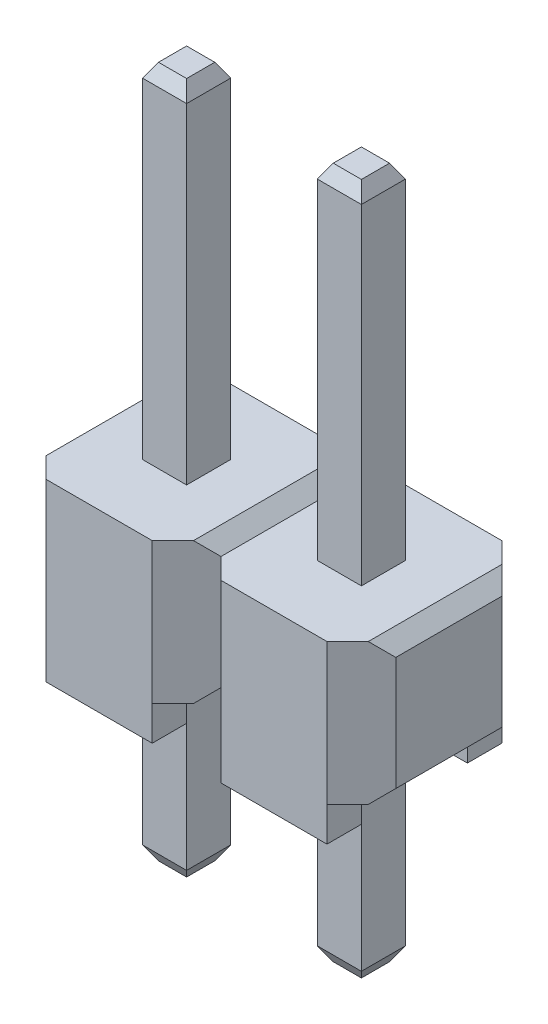
from build123d import *

# Parameters (mm, degrees)
SKETCH1_W                = 0.64
SKETCH1_H                = 0.64
BOSS_EXTRUDE1_DEPTH      = 2.05
CUT_EXTRUDE1_DEPTH       = 5
SKETCH3_W                = 1.54
SKETCH3_H                = 0.5
BOSS_EXTRUDE2_DEPTH      = 0.5
SKETCH4_W                = 0.64
SKETCH4_H                = 0.64
BOSS_EXTRUDE3_DEPTH      = 5
BOSS_EXTRUDE3_DEPTH_BACK = 5.05
CHAMFER1_SIZE            = 0.2
CHAMFER1_SIZE2           = 0.115470054
CHAMFER1_PART_2_SIZE     = 0.2
CHAMFER1_PART_2_SIZE2    = 0.115470054
CHAMFER1_PART_3_SIZE     = 0.2
CHAMFER1_PART_3_SIZE2    = 0.115470054
CHAMFER1_PART_4_SIZE     = 0.2
CHAMFER1_PART_4_SIZE2    = 0.115470054
CHAMFER1_PART_5_SIZE     = 0.2
CHAMFER1_PART_5_SIZE2    = 0.115470054
CHAMFER1_PART_6_SIZE     = 0.2
CHAMFER1_PART_6_SIZE2    = 0.115470054
CHAMFER1_PART_7_SIZE     = 0.2
CHAMFER1_PART_7_SIZE2    = 0.115470054
CHAMFER1_PART_8_SIZE     = 0.2
CHAMFER1_PART_8_SIZE2    = 0.115470054
CHAMFER1_PART_9_SIZE     = 0.2
CHAMFER1_PART_9_SIZE2    = 0.115470054
CHAMFER1_PART_10_SIZE    = 0.2
CHAMFER1_PART_10_SIZE2   = 0.115470054
CHAMFER1_PART_11_SIZE    = 0.2
CHAMFER1_PART_11_SIZE2   = 0.115470054
CHAMFER1_PART_12_SIZE    = 0.2
CHAMFER1_PART_12_SIZE2   = 0.115470054
CHAMFER1_PART_13_SIZE    = 0.2
CHAMFER1_PART_13_SIZE2   = 0.115470054
CHAMFER1_PART_14_SIZE    = 0.2
CHAMFER1_PART_14_SIZE2   = 0.115470054
CHAMFER1_PART_15_SIZE    = 0.2
CHAMFER1_PART_15_SIZE2   = 0.115470054
CHAMFER1_PART_16_SIZE    = 0.2
CHAMFER1_PART_16_SIZE2   = 0.115470054
SKETCH5_R                = 0.125
CUT_EXTRUDE2_DEPTH       = 1


with BuildPart() as part:
    # Sketch1 → Boss-Extrude1 (new body)
    with BuildSketch(Plane(origin=(0, 0, 0), x_dir=(1, 0, 0), z_dir=(0, 1, 0))):
        Polygon((-2.04, -1.27), (-0.5, -1.27), (0, -0.77), (0.5, -1.27), (2.04, -1.27), (2.54, -0.77), (2.54, 0.77), (2.04, 1.27), (0.5, 1.27), (0, 0.77), (-0.5, 1.27), (-2.04, 1.27), (-2.54, 0.77), (-2.54, -0.77), align=None)
        with Locations((1.27, 0)):
            Rectangle(SKETCH1_W, SKETCH1_H, mode=Mode.SUBTRACT)
        with Locations((-1.27, 0)):
            Rectangle(SKETCH1_W, SKETCH1_H, mode=Mode.SUBTRACT)
    extrude(amount=-BOSS_EXTRUDE1_DEPTH)

    # Sketch2 → Cut-Extrude1 (cut, symmetric)
    with BuildSketch(Plane.XY):
        Polygon((-2.54, -0.2), (-2.54, 0), (-2.34, 0), align=None)
        Polygon((-0.2, 0), (0.2, 0), (0, -0.2), align=None)
        Polygon((2.34, 0), (2.54, 0), (2.54, -0.2), align=None)
        Polygon((-2.54, -1.85), (-2.34, -2.05), (-2.54, -2.05), align=None)
        Polygon((-0.2, -2.05), (0, -1.85), (0.2, -2.05), align=None)
        Polygon((2.34, -2.05), (2.54, -1.85), (2.54, -2.05), align=None)
    extrude(amount=CUT_EXTRUDE1_DEPTH, both=True, mode=Mode.SUBTRACT)

    # Sketch3 → Boss-Extrude2 (add)
    with BuildSketch(Plane.XZ.offset(2.05)):
        with Locations((-1.27, -1.02)):
            Rectangle(SKETCH3_W, SKETCH3_H)
        with Locations((-1.27, 1.02)):
            Rectangle(SKETCH3_W, SKETCH3_H)
        with Locations((1.27, 1.02)):
            Rectangle(SKETCH3_W, SKETCH3_H)
        with Locations((1.27, -1.02)):
            Rectangle(SKETCH3_W, SKETCH3_H)
    extrude(amount=BOSS_EXTRUDE2_DEPTH)

    # Sketch4 → Boss-Extrude3 (add, two sides)
    with BuildSketch(Plane(origin=(0, 0, 0), x_dir=(1, 0, 0), z_dir=(0, 1, 0))) as boss_extrude3_sk:
        with Locations((-1.27, 0)):
            Rectangle(SKETCH4_W, SKETCH4_H)
        with Locations((1.27, 0)):
            Rectangle(SKETCH4_W, SKETCH4_H)
    extrude(amount=BOSS_EXTRUDE3_DEPTH)
    extrude(boss_extrude3_sk.sketch, amount=-BOSS_EXTRUDE3_DEPTH_BACK)

    # Chamfer1
    chamfer1_edges = [part.edges().sort_by_distance(p)[0] for p in [
        (-1.59, -5.05, 0),
    ]]
    chamfer1_side = [part.faces().sort_by_distance(p)[0] for p in [
        (-1.59, -3.55, 0),
    ]]
    chamfer(chamfer1_edges, length=CHAMFER1_SIZE, length2=CHAMFER1_SIZE2, reference=chamfer1_side[0])

    # Chamfer1 part 2
    chamfer1_part_2_edges = [part.edges().sort_by_distance(p)[0] for p in [
        (-1.27, -5.05, -0.32),
    ]]
    chamfer1_part_2_side = [part.faces().sort_by_distance(p)[0] for p in [
        (-1.27, -3.55, -0.32),
    ]]
    chamfer(chamfer1_part_2_edges, length=CHAMFER1_PART_2_SIZE, length2=CHAMFER1_PART_2_SIZE2, reference=chamfer1_part_2_side[0])

    # Chamfer1 part 3
    chamfer1_part_3_edges = [part.edges().sort_by_distance(p)[0] for p in [
        (-0.95, -5.05, 0),
    ]]
    chamfer1_part_3_side = [part.faces().sort_by_distance(p)[0] for p in [
        (-0.95, -3.55, 0),
    ]]
    chamfer(chamfer1_part_3_edges, length=CHAMFER1_PART_3_SIZE, length2=CHAMFER1_PART_3_SIZE2, reference=chamfer1_part_3_side[0])

    # Chamfer1 part 4
    chamfer1_part_4_edges = [part.edges().sort_by_distance(p)[0] for p in [
        (-1.27, -5.05, 0.32),
    ]]
    chamfer1_part_4_side = [part.faces().sort_by_distance(p)[0] for p in [
        (-1.27, -3.55, 0.32),
    ]]
    chamfer(chamfer1_part_4_edges, length=CHAMFER1_PART_4_SIZE, length2=CHAMFER1_PART_4_SIZE2, reference=chamfer1_part_4_side[0])

    # Chamfer1 part 5
    chamfer1_part_5_edges = [part.edges().sort_by_distance(p)[0] for p in [
        (-1.59, 5, 0),
    ]]
    chamfer1_part_5_side = [part.faces().sort_by_distance(p)[0] for p in [
        (-1.59, 2.5, 0),
    ]]
    chamfer(chamfer1_part_5_edges, length=CHAMFER1_PART_5_SIZE, length2=CHAMFER1_PART_5_SIZE2, reference=chamfer1_part_5_side[0])

    # Chamfer1 part 6
    chamfer1_part_6_edges = [part.edges().sort_by_distance(p)[0] for p in [
        (-1.27, 5, 0.32),
    ]]
    chamfer1_part_6_side = [part.faces().sort_by_distance(p)[0] for p in [
        (-1.27, 2.5, 0.32),
    ]]
    chamfer(chamfer1_part_6_edges, length=CHAMFER1_PART_6_SIZE, length2=CHAMFER1_PART_6_SIZE2, reference=chamfer1_part_6_side[0])

    # Chamfer1 part 7
    chamfer1_part_7_edges = [part.edges().sort_by_distance(p)[0] for p in [
        (-0.95, 5, 0),
    ]]
    chamfer1_part_7_side = [part.faces().sort_by_distance(p)[0] for p in [
        (-0.95, 2.5, 0),
    ]]
    chamfer(chamfer1_part_7_edges, length=CHAMFER1_PART_7_SIZE, length2=CHAMFER1_PART_7_SIZE2, reference=chamfer1_part_7_side[0])

    # Chamfer1 part 8
    chamfer1_part_8_edges = [part.edges().sort_by_distance(p)[0] for p in [
        (-1.27, 5, -0.32),
    ]]
    chamfer1_part_8_side = [part.faces().sort_by_distance(p)[0] for p in [
        (-1.27, 2.5, -0.32),
    ]]
    chamfer(chamfer1_part_8_edges, length=CHAMFER1_PART_8_SIZE, length2=CHAMFER1_PART_8_SIZE2, reference=chamfer1_part_8_side[0])

    # Chamfer1 part 9
    chamfer1_part_9_edges = [part.edges().sort_by_distance(p)[0] for p in [
        (0.95, -5.05, 0),
    ]]
    chamfer1_part_9_side = [part.faces().sort_by_distance(p)[0] for p in [
        (0.95, -3.55, 0),
    ]]
    chamfer(chamfer1_part_9_edges, length=CHAMFER1_PART_9_SIZE, length2=CHAMFER1_PART_9_SIZE2, reference=chamfer1_part_9_side[0])

    # Chamfer1 part 10
    chamfer1_part_10_edges = [part.edges().sort_by_distance(p)[0] for p in [
        (1.27, -5.05, -0.32),
    ]]
    chamfer1_part_10_side = [part.faces().sort_by_distance(p)[0] for p in [
        (1.27, -3.55, -0.32),
    ]]
    chamfer(chamfer1_part_10_edges, length=CHAMFER1_PART_10_SIZE, length2=CHAMFER1_PART_10_SIZE2, reference=chamfer1_part_10_side[0])

    # Chamfer1 part 11
    chamfer1_part_11_edges = [part.edges().sort_by_distance(p)[0] for p in [
        (1.59, -5.05, 0),
    ]]
    chamfer1_part_11_side = [part.faces().sort_by_distance(p)[0] for p in [
        (1.59, -3.55, 0),
    ]]
    chamfer(chamfer1_part_11_edges, length=CHAMFER1_PART_11_SIZE, length2=CHAMFER1_PART_11_SIZE2, reference=chamfer1_part_11_side[0])

    # Chamfer1 part 12
    chamfer1_part_12_edges = [part.edges().sort_by_distance(p)[0] for p in [
        (1.27, -5.05, 0.32),
    ]]
    chamfer1_part_12_side = [part.faces().sort_by_distance(p)[0] for p in [
        (1.27, -3.55, 0.32),
    ]]
    chamfer(chamfer1_part_12_edges, length=CHAMFER1_PART_12_SIZE, length2=CHAMFER1_PART_12_SIZE2, reference=chamfer1_part_12_side[0])

    # Chamfer1 part 13
    chamfer1_part_13_edges = [part.edges().sort_by_distance(p)[0] for p in [
        (0.95, 5, 0),
    ]]
    chamfer1_part_13_side = [part.faces().sort_by_distance(p)[0] for p in [
        (0.95, 2.5, 0),
    ]]
    chamfer(chamfer1_part_13_edges, length=CHAMFER1_PART_13_SIZE, length2=CHAMFER1_PART_13_SIZE2, reference=chamfer1_part_13_side[0])

    # Chamfer1 part 14
    chamfer1_part_14_edges = [part.edges().sort_by_distance(p)[0] for p in [
        (1.27, 5, 0.32),
    ]]
    chamfer1_part_14_side = [part.faces().sort_by_distance(p)[0] for p in [
        (1.27, 2.5, 0.32),
    ]]
    chamfer(chamfer1_part_14_edges, length=CHAMFER1_PART_14_SIZE, length2=CHAMFER1_PART_14_SIZE2, reference=chamfer1_part_14_side[0])

    # Chamfer1 part 15
    chamfer1_part_15_edges = [part.edges().sort_by_distance(p)[0] for p in [
        (1.59, 5, 0),
    ]]
    chamfer1_part_15_side = [part.faces().sort_by_distance(p)[0] for p in [
        (1.59, 2.5, 0),
    ]]
    chamfer(chamfer1_part_15_edges, length=CHAMFER1_PART_15_SIZE, length2=CHAMFER1_PART_15_SIZE2, reference=chamfer1_part_15_side[0])

    # Chamfer1 part 16
    chamfer1_part_16_edges = [part.edges().sort_by_distance(p)[0] for p in [
        (1.27, 5, -0.32),
    ]]
    chamfer1_part_16_side = [part.faces().sort_by_distance(p)[0] for p in [
        (1.27, 2.5, -0.32),
    ]]
    chamfer(chamfer1_part_16_edges, length=CHAMFER1_PART_16_SIZE, length2=CHAMFER1_PART_16_SIZE2, reference=chamfer1_part_16_side[0])

    # Sketch5 → Cut-Extrude2 (cut)
    with BuildSketch(Plane.XZ.offset(5.05)):
        with Locations((-1.27, 0)):
            Circle(SKETCH5_R)
    extrude(amount=-CUT_EXTRUDE2_DEPTH, mode=Mode.SUBTRACT)


solid = part.part
